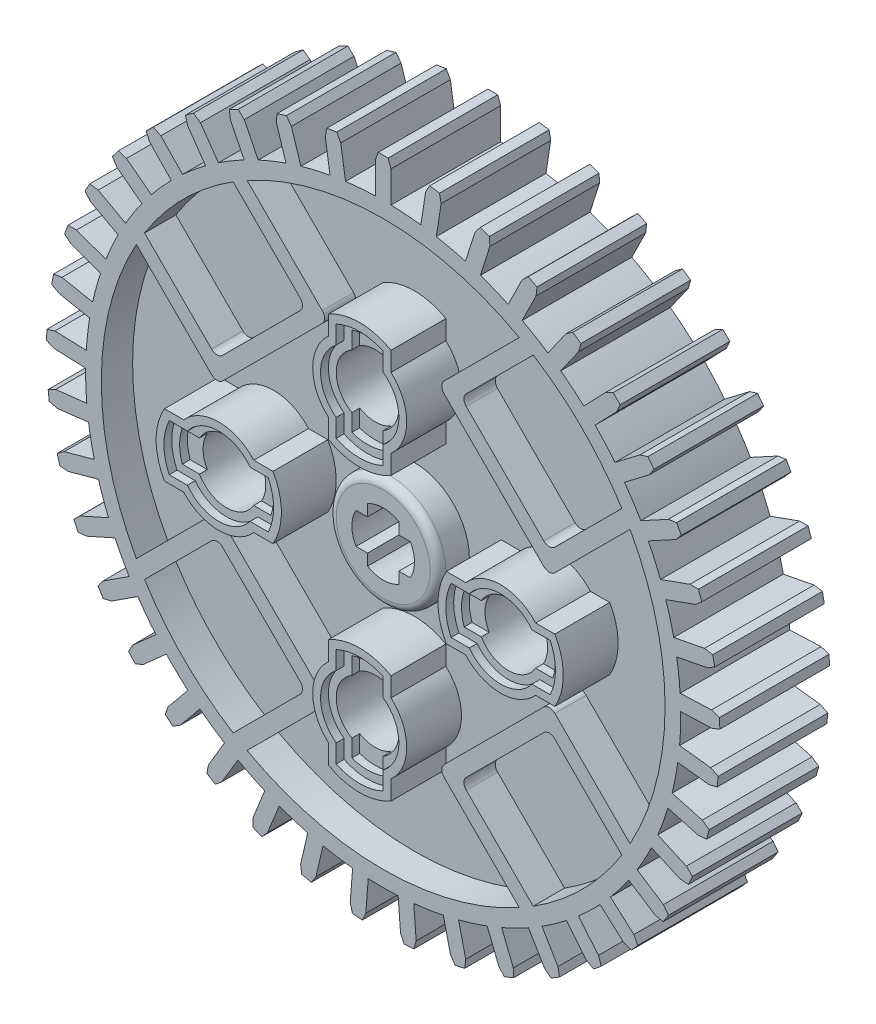
from build123d import *

# Parameters (mm, degrees)
SKETCH1_R                = 19
SKETCH1_R_2              = 2
BOSS_EXTRUDE1_DEPTH      = 3.5
SKETCH3_R                = 18
SKETCH3_R_2              = 3.5
CUT_EXTRUDE1_DEPTH       = 2
BOSS_EXTRUDE2_START      = -5
BOSS_EXTRUDE2_DEPTH      = 7
FILLET2_R                = 0.5
CIRPATTERN5_COUNT        = 4
FILLET2_OF_CIRPATTERN5_R = 0.5
BOSS_EXTRUDE3_DEPTH      = 3
CUT_EXTRUDE3_DEPTH       = 0.5
SKETCH8_R                = 2
CUT_EXTRUDE4_DEPTH       = 28.897132469
BOSS_EXTRUDE5_START      = -3
BOSS_EXTRUDE5_DEPTH      = 3.5
CIRPATTERN2_COUNT        = 4
MIRROR6_COPY_1_DEPTH     = 3
MIRROR6_COPY_2_DEPTH     = 3
MIRROR6_COPY_3_DEPTH     = 3
MIRROR6_COPY_4_DEPTH     = 0.5
MIRROR6_COPY_5_DEPTH     = 0.5
MIRROR6_COPY_6_DEPTH     = 0.5
MIRROR6_COPY_7_SKETCH_R  = 2
MIRROR6_COPY_7_DEPTH     = 28.897132469
MIRROR6_COPY_8_SKETCH_R  = 2
MIRROR6_COPY_8_DEPTH     = 28.897132469
MIRROR6_COPY_9_SKETCH_R  = 2
MIRROR6_COPY_9_DEPTH     = 28.897132469
MIRROR6_START            = -3
MIRROR6_COPY_10_DEPTH    = 3.5
MIRROR6_COPY_11_DEPTH    = 3.5
MIRROR6_COPY_12_DEPTH    = 3.5
MIRROR6_COPY_13_SKETCH_R = 2
MIRROR6_COPY_13_DEPTH    = 28.897132469
BOSS_EXTRUDE6_START      = -3.5
BOSS_EXTRUDE6_DEPTH      = 7
CIRPATTERN7_COUNT        = 41
FILLET3_R                = 0.5


with BuildPart() as part:
    # Sketch1 → Boss-Extrude1 (new, symmetric)
    with BuildSketch(Plane.XY):
        Circle(SKETCH1_R)
        Circle(SKETCH1_R_2, mode=Mode.SUBTRACT)
        with BuildLine():
            Line((1, -1), (1, -1.732050808))
            ThreePointArc((1, -1.732050808), (1.414213562, -1.414213562), (1.732050808, -1))
            Line((1.732050808, -1), (1, -1))
        make_face()
        with BuildLine():
            ThreePointArc((-1.732050808, -1), (-1.414213562, -1.414213562), (-1, -1.732050808))
            Line((-1, -1.732050808), (-1, -1))
            Line((-1, -1), (-1.732050808, -1))
        make_face()
        with BuildLine():
            Line((-1.732050808, 1), (-1, 1))
            Line((-1, 1), (-1, 1.732050808))
            ThreePointArc((-1, 1.732050808), (-1.414213562, 1.414213562), (-1.732050808, 1))
        make_face()
        with BuildLine():
            Line((1, 1.732050808), (1, 1))
            Line((1, 1), (1.732050808, 1))
            ThreePointArc((1.732050808, 1), (1.414213562, 1.414213562), (1, 1.732050808))
        make_face()
    extrude(amount=BOSS_EXTRUDE1_DEPTH, both=True)

    # Sketch3 → Cut-Extrude1 (cut)
    with BuildSketch(Plane.XY.offset(3.5)):
        Circle(SKETCH3_R)
        Circle(SKETCH3_R_2, mode=Mode.SUBTRACT)
    cut_extrude1 = extrude(amount=-CUT_EXTRUDE1_DEPTH, mode=Mode.SUBTRACT)

    # Mirror2: Cut-Extrude1 across plane
    add(cut_extrude1.mirror(Plane.XY), mode=Mode.SUBTRACT)

    # Sketch4 → Boss-Extrude2 (add)
    with BuildSketch(Plane.XY.offset(1.5).offset(BOSS_EXTRUDE2_START)):
        with BuildLine():
            Line((9.581246521, 15.238100771), (4.949747468, 10.606601718))
            Line((4.949747468, 10.606601718), (10.606601718, 4.949747468))
            Line((10.606601718, 4.949747468), (15.238100771, 9.581246521))
            ThreePointArc((15.238100771, 9.581246521), (15.506709995, 9.140128289), (15.762553167, 8.691485355))
            Line((15.762553167, 8.691485355), (10.606601718, 3.535533906))
            Line((10.606601718, 3.535533906), (3.535533906, 10.606601718))
            Line((3.535533906, 10.606601718), (8.691485355, 15.762553167))
            ThreePointArc((8.691485355, 15.762553167), (9.140128289, 15.506709995), (9.581246521, 15.238100771))
        make_face()
    boss_extrude2 = extrude(amount=BOSS_EXTRUDE2_DEPTH)

    # Fillet2
    fillet2_edges = [part.edges().sort_by_distance(p)[0] for p in [
        (3.535533906, 10.606601718, 2.5),
        (10.606601718, 4.949747468, 2.5),
        (10.606601718, 3.535533906, 2.5),
        (4.949747468, 10.606601718, 2.5),
        (3.535533906, 10.606601718, -2.5),
        (10.606601718, 3.535533906, -2.5),
        (10.606601718, 4.949747468, -2.5),
        (4.949747468, 10.606601718, -2.5),
    ]]
    fillet(fillet2_edges, radius=FILLET2_R)

    # CirPattern5: Boss-Extrude2 ×4 about axis
    cirpattern5_axis = Axis((0, 0, 0), (0, 0, 1))
    for i in range(1, CIRPATTERN5_COUNT):
        add(boss_extrude2.rotate(cirpattern5_axis, i * 360 / CIRPATTERN5_COUNT))

    # Fillet2 of CirPattern5
    fillet2_of_cirpattern5_edges = [part.edges().sort_by_distance(p)[0] for p in [
        (-10.606601718, 3.535533906, 2.5),
        (-4.949747468, 10.606601718, 2.5),
        (-3.535533906, 10.606601718, 2.5),
        (-10.606601718, 4.949747468, 2.5),
        (-10.606601718, 3.535533906, -2.5),
        (-3.535533906, 10.606601718, -2.5),
        (-4.949747468, 10.606601718, -2.5),
        (-10.606601718, 4.949747468, -2.5),
        (-3.535533906, -10.606601718, 2.5),
        (-10.606601718, -4.949747468, 2.5),
        (-10.606601718, -3.535533906, 2.5),
        (-4.949747468, -10.606601718, 2.5),
        (-3.535533906, -10.606601718, -2.5),
        (-10.606601718, -3.535533906, -2.5),
        (-10.606601718, -4.949747468, -2.5),
        (-4.949747468, -10.606601718, -2.5),
        (10.606601718, -3.535533906, 2.5),
        (4.949747468, -10.606601718, 2.5),
        (3.535533906, -10.606601718, 2.5),
        (10.606601718, -4.949747468, 2.5),
        (10.606601718, -3.535533906, -2.5),
        (3.535533906, -10.606601718, -2.5),
        (4.949747468, -10.606601718, -2.5),
        (10.606601718, -4.949747468, -2.5),
    ]]
    fillet(fillet2_of_cirpattern5_edges, radius=FILLET2_OF_CIRPATTERN5_R)

    # Sketch5 → Boss-Extrude3 (add)
    with BuildSketch(Plane.XY.offset(1.5)):
        with BuildLine():
            ThreePointArc((-1.5, 11), (-2.5, 9), (-1.5, 7))
            Line((-1.5, 7), (-1.5, 11))
        make_face()
        with BuildLine():
            Line((1.5, 11), (1.5, 7))
            ThreePointArc((1.5, 7), (2.236067977, 7.881966011), (2.5, 9))
            ThreePointArc((2.5, 9), (2.236067977, 10.118033989), (1.5, 11))
        make_face()
        with BuildLine():
            Line((-1.5, 7), (-1.5, 5.83772234))
            Line((-1.5, 5.83772234), (1.5, 5.83772234))
            Line((1.5, 5.83772234), (1.5, 7))
            ThreePointArc((1.5, 7), (0, 6.5), (-1.5, 7))
        make_face()
        with BuildLine():
            Line((1.5, 5.83772234), (-1.5, 5.83772234))
            ThreePointArc((-1.5, 5.83772234), (0, 5.5), (1.5, 5.83772234))
        make_face()
        with BuildLine():
            Line((1.5, 12.16227766), (-1.5, 12.16227766))
            Line((-1.5, 12.16227766), (-1.5, 11))
            ThreePointArc((-1.5, 11), (0, 11.5), (1.5, 11))
            Line((1.5, 11), (1.5, 12.16227766))
        make_face()
        with BuildLine():
            ThreePointArc((1.5, 12.16227766), (0, 12.5), (-1.5, 12.16227766))
            Line((-1.5, 12.16227766), (1.5, 12.16227766))
        make_face()
        with BuildLine():
            Line((-1.5, 11), (-1.5, 7))
            ThreePointArc((-1.5, 7), (0, 6.5), (1.5, 7))
            Line((1.5, 7), (1.5, 11))
            ThreePointArc((1.5, 11), (0, 11.5), (-1.5, 11))
        make_face()
    boss_extrude3 = extrude(amount=BOSS_EXTRUDE3_DEPTH)

    # Sketch7 → Cut-Extrude3 (cut)
    with BuildSketch(Plane.XY.offset(4.5)):
        with BuildLine():
            Line((-1, 7.267949192), (-1, 6.171572875))
            ThreePointArc((-1, 6.171572875), (0, 6), (1, 6.171572875))
            Line((1, 6.171572875), (1, 7.267949192))
            ThreePointArc((1, 7.267949192), (2, 9), (1, 10.732050808))
            Line((1, 10.732050808), (1, 11.828427125))
            ThreePointArc((1, 11.828427125), (0, 12), (-1, 11.828427125))
            Line((-1, 11.828427125), (-1, 10.732050808))
            ThreePointArc((-1, 10.732050808), (-2, 9), (-1, 7.267949192))
        make_face()
    cut_extrude3 = extrude(amount=-CUT_EXTRUDE3_DEPTH, mode=Mode.SUBTRACT)

    # Sketch8 → Cut-Extrude4 (cut, symmetric)
    with BuildSketch(Plane.XY.offset(4)):
        with Locations(Location((0, 9, 0), (0, 0, 300))):
            Circle(SKETCH8_R)
    cut_extrude4 = extrude(amount=CUT_EXTRUDE4_DEPTH, both=True, mode=Mode.SUBTRACT)

    # Sketch9 → Boss-Extrude5 (add)
    with BuildSketch(Plane.XY.offset(4.5).offset(BOSS_EXTRUDE5_START)):
        with BuildLine():
            Line((-2, 6.763932023), (-2, 5.535898385))
            ThreePointArc((-2, 5.535898385), (0, 5), (2, 5.535898385))
            Line((2, 5.535898385), (2, 6.763932023))
            ThreePointArc((2, 6.763932023), (3, 9), (2, 11.236067977))
            Line((2, 11.236067977), (2, 12.464101615))
            ThreePointArc((2, 12.464101615), (0, 13), (-2, 12.464101615))
            Line((-2, 12.464101615), (-2, 11.236067977))
            ThreePointArc((-2, 11.236067977), (-3, 9), (-2, 6.763932023))
        make_face()
        with BuildLine():
            Line((-1.5, 7), (-1.5, 5.83772234))
            ThreePointArc((-1.5, 5.83772234), (0, 5.5), (1.5, 5.83772234))
            Line((1.5, 5.83772234), (1.5, 7))
            ThreePointArc((1.5, 7), (2.5, 9), (1.5, 11))
            Line((1.5, 11), (1.5, 12.16227766))
            ThreePointArc((1.5, 12.16227766), (0, 12.5), (-1.5, 12.16227766))
            Line((-1.5, 12.16227766), (-1.5, 11))
            ThreePointArc((-1.5, 11), (-2.5, 9), (-1.5, 7))
        make_face(mode=Mode.SUBTRACT)
    boss_extrude5 = extrude(amount=BOSS_EXTRUDE5_DEPTH)

    # CirPattern2: Boss-Extrude3, Cut-Extrude3, Cut-Extrude4, Boss-Extrude5 ×4 about axis
    cirpattern2_axis = Axis((0, 0, 0), (0, 0, 1))
    add([boss_extrude3.rotate(cirpattern2_axis, i * 360 / CIRPATTERN2_COUNT) for i in range(1, CIRPATTERN2_COUNT)])
    add([cut_extrude3.rotate(cirpattern2_axis, i * 360 / CIRPATTERN2_COUNT) for i in range(1, CIRPATTERN2_COUNT)], mode=Mode.SUBTRACT)
    add([cut_extrude4.rotate(cirpattern2_axis, i * 360 / CIRPATTERN2_COUNT) for i in range(1, CIRPATTERN2_COUNT)], mode=Mode.SUBTRACT)
    add([boss_extrude5.rotate(cirpattern2_axis, i * 360 / CIRPATTERN2_COUNT) for i in range(1, CIRPATTERN2_COUNT)])

    # Mirror6: Boss-Extrude3, Cut-Extrude3, Boss-Extrude5 across plane
    add(boss_extrude3.mirror(Plane.XY))
    add(cut_extrude3.mirror(Plane.XY), mode=Mode.SUBTRACT)
    add(boss_extrude5.mirror(Plane.XY))

    # Mirror6 copy 1 sketch → Mirror6 copy 1 (add)
    with BuildSketch(Plane.YX.offset(1.5)):
        with BuildLine():
            ThreePointArc((-1.5, -11), (-2.5, -9), (-1.5, -7))
            Line((-1.5, -7), (-1.5, -11))
        make_face()
        with BuildLine():
            Line((1.5, -11), (1.5, -7))
            ThreePointArc((1.5, -7), (2.236067977, -7.881966011), (2.5, -9))
            ThreePointArc((2.5, -9), (2.236067977, -10.118033989), (1.5, -11))
        make_face()
        with BuildLine():
            Line((-1.5, -7), (-1.5, -5.83772234))
            Line((-1.5, -5.83772234), (1.5, -5.83772234))
            Line((1.5, -5.83772234), (1.5, -7))
            ThreePointArc((1.5, -7), (0, -6.5), (-1.5, -7))
        make_face()
        with BuildLine():
            Line((1.5, -5.83772234), (-1.5, -5.83772234))
            ThreePointArc((-1.5, -5.83772234), (0, -5.5), (1.5, -5.83772234))
        make_face()
        with BuildLine():
            Line((1.5, -12.16227766), (-1.5, -12.16227766))
            Line((-1.5, -12.16227766), (-1.5, -11))
            ThreePointArc((-1.5, -11), (0, -11.5), (1.5, -11))
            Line((1.5, -11), (1.5, -12.16227766))
        make_face()
        with BuildLine():
            ThreePointArc((1.5, -12.16227766), (0, -12.5), (-1.5, -12.16227766))
            Line((-1.5, -12.16227766), (1.5, -12.16227766))
        make_face()
        with BuildLine():
            Line((-1.5, -11), (-1.5, -7))
            ThreePointArc((-1.5, -7), (0, -6.5), (1.5, -7))
            Line((1.5, -7), (1.5, -11))
            ThreePointArc((1.5, -11), (0, -11.5), (-1.5, -11))
        make_face()
    extrude(amount=MIRROR6_COPY_1_DEPTH)

    # Mirror6 copy 2 sketch → Mirror6 copy 2 (add)
    with BuildSketch(Plane(origin=(0, 0, -1.5), x_dir=(-1, 0, 0), z_dir=(0, 0, -1))):
        with BuildLine():
            ThreePointArc((-1.5, -11), (-2.5, -9), (-1.5, -7))
            Line((-1.5, -7), (-1.5, -11))
        make_face()
        with BuildLine():
            Line((1.5, -11), (1.5, -7))
            ThreePointArc((1.5, -7), (2.236067977, -7.881966011), (2.5, -9))
            ThreePointArc((2.5, -9), (2.236067977, -10.118033989), (1.5, -11))
        make_face()
        with BuildLine():
            Line((-1.5, -7), (-1.5, -5.83772234))
            Line((-1.5, -5.83772234), (1.5, -5.83772234))
            Line((1.5, -5.83772234), (1.5, -7))
            ThreePointArc((1.5, -7), (0, -6.5), (-1.5, -7))
        make_face()
        with BuildLine():
            Line((1.5, -5.83772234), (-1.5, -5.83772234))
            ThreePointArc((-1.5, -5.83772234), (0, -5.5), (1.5, -5.83772234))
        make_face()
        with BuildLine():
            Line((1.5, -12.16227766), (-1.5, -12.16227766))
            Line((-1.5, -12.16227766), (-1.5, -11))
            ThreePointArc((-1.5, -11), (0, -11.5), (1.5, -11))
            Line((1.5, -11), (1.5, -12.16227766))
        make_face()
        with BuildLine():
            ThreePointArc((1.5, -12.16227766), (0, -12.5), (-1.5, -12.16227766))
            Line((-1.5, -12.16227766), (1.5, -12.16227766))
        make_face()
        with BuildLine():
            Line((-1.5, -11), (-1.5, -7))
            ThreePointArc((-1.5, -7), (0, -6.5), (1.5, -7))
            Line((1.5, -7), (1.5, -11))
            ThreePointArc((1.5, -11), (0, -11.5), (-1.5, -11))
        make_face()
    extrude(amount=MIRROR6_COPY_2_DEPTH)

    # Mirror6 copy 3 sketch → Mirror6 copy 3 (add)
    with BuildSketch(Plane(origin=(0, 0, -1.5), x_dir=(0, -1, 0), z_dir=(0, 0, -1))):
        with BuildLine():
            ThreePointArc((-1.5, -11), (-2.5, -9), (-1.5, -7))
            Line((-1.5, -7), (-1.5, -11))
        make_face()
        with BuildLine():
            Line((1.5, -11), (1.5, -7))
            ThreePointArc((1.5, -7), (2.236067977, -7.881966011), (2.5, -9))
            ThreePointArc((2.5, -9), (2.236067977, -10.118033989), (1.5, -11))
        make_face()
        with BuildLine():
            Line((-1.5, -7), (-1.5, -5.83772234))
            Line((-1.5, -5.83772234), (1.5, -5.83772234))
            Line((1.5, -5.83772234), (1.5, -7))
            ThreePointArc((1.5, -7), (0, -6.5), (-1.5, -7))
        make_face()
        with BuildLine():
            Line((1.5, -5.83772234), (-1.5, -5.83772234))
            ThreePointArc((-1.5, -5.83772234), (0, -5.5), (1.5, -5.83772234))
        make_face()
        with BuildLine():
            Line((1.5, -12.16227766), (-1.5, -12.16227766))
            Line((-1.5, -12.16227766), (-1.5, -11))
            ThreePointArc((-1.5, -11), (0, -11.5), (1.5, -11))
            Line((1.5, -11), (1.5, -12.16227766))
        make_face()
        with BuildLine():
            ThreePointArc((1.5, -12.16227766), (0, -12.5), (-1.5, -12.16227766))
            Line((-1.5, -12.16227766), (1.5, -12.16227766))
        make_face()
        with BuildLine():
            Line((-1.5, -11), (-1.5, -7))
            ThreePointArc((-1.5, -7), (0, -6.5), (1.5, -7))
            Line((1.5, -7), (1.5, -11))
            ThreePointArc((1.5, -11), (0, -11.5), (-1.5, -11))
        make_face()
    extrude(amount=MIRROR6_COPY_3_DEPTH)

    # Mirror6 copy 4 sketch → Mirror6 copy 4 (cut)
    with BuildSketch(Plane.YX.offset(4.5)):
        with BuildLine():
            Line((-1, -7.267949192), (-1, -6.171572875))
            ThreePointArc((-1, -6.171572875), (0, -6), (1, -6.171572875))
            Line((1, -6.171572875), (1, -7.267949192))
            ThreePointArc((1, -7.267949192), (2, -9), (1, -10.732050808))
            Line((1, -10.732050808), (1, -11.828427125))
            ThreePointArc((1, -11.828427125), (0, -12), (-1, -11.828427125))
            Line((-1, -11.828427125), (-1, -10.732050808))
            ThreePointArc((-1, -10.732050808), (-2, -9), (-1, -7.267949192))
        make_face()
    extrude(amount=-MIRROR6_COPY_4_DEPTH, mode=Mode.SUBTRACT)

    # Mirror6 copy 5 sketch → Mirror6 copy 5 (cut)
    with BuildSketch(Plane(origin=(0, 0, -4.5), x_dir=(-1, 0, 0), z_dir=(0, 0, -1))):
        with BuildLine():
            Line((-1, -7.267949192), (-1, -6.171572875))
            ThreePointArc((-1, -6.171572875), (0, -6), (1, -6.171572875))
            Line((1, -6.171572875), (1, -7.267949192))
            ThreePointArc((1, -7.267949192), (2, -9), (1, -10.732050808))
            Line((1, -10.732050808), (1, -11.828427125))
            ThreePointArc((1, -11.828427125), (0, -12), (-1, -11.828427125))
            Line((-1, -11.828427125), (-1, -10.732050808))
            ThreePointArc((-1, -10.732050808), (-2, -9), (-1, -7.267949192))
        make_face()
    extrude(amount=-MIRROR6_COPY_5_DEPTH, mode=Mode.SUBTRACT)

    # Mirror6 copy 6 sketch → Mirror6 copy 6 (cut)
    with BuildSketch(Plane(origin=(0, 0, -4.5), x_dir=(0, -1, 0), z_dir=(0, 0, -1))):
        with BuildLine():
            Line((-1, -7.267949192), (-1, -6.171572875))
            ThreePointArc((-1, -6.171572875), (0, -6), (1, -6.171572875))
            Line((1, -6.171572875), (1, -7.267949192))
            ThreePointArc((1, -7.267949192), (2, -9), (1, -10.732050808))
            Line((1, -10.732050808), (1, -11.828427125))
            ThreePointArc((1, -11.828427125), (0, -12), (-1, -11.828427125))
            Line((-1, -11.828427125), (-1, -10.732050808))
            ThreePointArc((-1, -10.732050808), (-2, -9), (-1, -7.267949192))
        make_face()
    extrude(amount=-MIRROR6_COPY_6_DEPTH, mode=Mode.SUBTRACT)

    # Mirror6 copy 7 sketch → Mirror6 copy 7 (cut, symmetric)
    with BuildSketch(Plane.YX.offset(4)):
        with Locations((0, -9)):
            Circle(MIRROR6_COPY_7_SKETCH_R)
    extrude(amount=MIRROR6_COPY_7_DEPTH, both=True, mode=Mode.SUBTRACT)

    # Mirror6 copy 8 sketch → Mirror6 copy 8 (cut, symmetric)
    with BuildSketch(Plane(origin=(0, 0, -4), x_dir=(-1, 0, 0), z_dir=(0, 0, -1))):
        with Locations((0, -9)):
            Circle(MIRROR6_COPY_8_SKETCH_R)
    extrude(amount=MIRROR6_COPY_8_DEPTH, both=True, mode=Mode.SUBTRACT)

    # Mirror6 copy 9 sketch → Mirror6 copy 9 (cut, symmetric)
    with BuildSketch(Plane(origin=(0, 0, -4), x_dir=(0, -1, 0), z_dir=(0, 0, -1))):
        with Locations((0, -9)):
            Circle(MIRROR6_COPY_9_SKETCH_R)
    extrude(amount=MIRROR6_COPY_9_DEPTH, both=True, mode=Mode.SUBTRACT)

    # Mirror6 copy 10 sketch → Mirror6 copy 10 (add)
    with BuildSketch(Plane.YX.offset(4.5).offset(MIRROR6_START)):
        with BuildLine():
            Line((-2, -6.763932023), (-2, -5.535898385))
            ThreePointArc((-2, -5.535898385), (0, -5), (2, -5.535898385))
            Line((2, -5.535898385), (2, -6.763932023))
            ThreePointArc((2, -6.763932023), (3, -9), (2, -11.236067977))
            Line((2, -11.236067977), (2, -12.464101615))
            ThreePointArc((2, -12.464101615), (0, -13), (-2, -12.464101615))
            Line((-2, -12.464101615), (-2, -11.236067977))
            ThreePointArc((-2, -11.236067977), (-3, -9), (-2, -6.763932023))
        make_face()
        with BuildLine():
            Line((-1.5, -7), (-1.5, -5.83772234))
            ThreePointArc((-1.5, -5.83772234), (0, -5.5), (1.5, -5.83772234))
            Line((1.5, -5.83772234), (1.5, -7))
            ThreePointArc((1.5, -7), (2.5, -9), (1.5, -11))
            Line((1.5, -11), (1.5, -12.16227766))
            ThreePointArc((1.5, -12.16227766), (0, -12.5), (-1.5, -12.16227766))
            Line((-1.5, -12.16227766), (-1.5, -11))
            ThreePointArc((-1.5, -11), (-2.5, -9), (-1.5, -7))
        make_face(mode=Mode.SUBTRACT)
    extrude(amount=MIRROR6_COPY_10_DEPTH)

    # Mirror6 copy 11 sketch → Mirror6 copy 11 (add)
    with BuildSketch(Plane(origin=(0, 0, -4.5), x_dir=(-1, 0, 0), z_dir=(0, 0, -1)).offset(MIRROR6_START)):
        with BuildLine():
            Line((-2, -6.763932023), (-2, -5.535898385))
            ThreePointArc((-2, -5.535898385), (0, -5), (2, -5.535898385))
            Line((2, -5.535898385), (2, -6.763932023))
            ThreePointArc((2, -6.763932023), (3, -9), (2, -11.236067977))
            Line((2, -11.236067977), (2, -12.464101615))
            ThreePointArc((2, -12.464101615), (0, -13), (-2, -12.464101615))
            Line((-2, -12.464101615), (-2, -11.236067977))
            ThreePointArc((-2, -11.236067977), (-3, -9), (-2, -6.763932023))
        make_face()
        with BuildLine():
            Line((-1.5, -7), (-1.5, -5.83772234))
            ThreePointArc((-1.5, -5.83772234), (0, -5.5), (1.5, -5.83772234))
            Line((1.5, -5.83772234), (1.5, -7))
            ThreePointArc((1.5, -7), (2.5, -9), (1.5, -11))
            Line((1.5, -11), (1.5, -12.16227766))
            ThreePointArc((1.5, -12.16227766), (0, -12.5), (-1.5, -12.16227766))
            Line((-1.5, -12.16227766), (-1.5, -11))
            ThreePointArc((-1.5, -11), (-2.5, -9), (-1.5, -7))
        make_face(mode=Mode.SUBTRACT)
    extrude(amount=MIRROR6_COPY_11_DEPTH)

    # Mirror6 copy 12 sketch → Mirror6 copy 12 (add)
    with BuildSketch(Plane(origin=(0, 0, -4.5), x_dir=(0, -1, 0), z_dir=(0, 0, -1)).offset(MIRROR6_START)):
        with BuildLine():
            Line((-2, -6.763932023), (-2, -5.535898385))
            ThreePointArc((-2, -5.535898385), (0, -5), (2, -5.535898385))
            Line((2, -5.535898385), (2, -6.763932023))
            ThreePointArc((2, -6.763932023), (3, -9), (2, -11.236067977))
            Line((2, -11.236067977), (2, -12.464101615))
            ThreePointArc((2, -12.464101615), (0, -13), (-2, -12.464101615))
            Line((-2, -12.464101615), (-2, -11.236067977))
            ThreePointArc((-2, -11.236067977), (-3, -9), (-2, -6.763932023))
        make_face()
        with BuildLine():
            Line((-1.5, -7), (-1.5, -5.83772234))
            ThreePointArc((-1.5, -5.83772234), (0, -5.5), (1.5, -5.83772234))
            Line((1.5, -5.83772234), (1.5, -7))
            ThreePointArc((1.5, -7), (2.5, -9), (1.5, -11))
            Line((1.5, -11), (1.5, -12.16227766))
            ThreePointArc((1.5, -12.16227766), (0, -12.5), (-1.5, -12.16227766))
            Line((-1.5, -12.16227766), (-1.5, -11))
            ThreePointArc((-1.5, -11), (-2.5, -9), (-1.5, -7))
        make_face(mode=Mode.SUBTRACT)
    extrude(amount=MIRROR6_COPY_12_DEPTH)

    # Mirror6 copy 13 sketch → Mirror6 copy 13 (cut, symmetric)
    with BuildSketch(Plane(origin=(0, 0, -4), x_dir=(1, 0, 0), z_dir=(0, 0, -1))):
        with Locations((0, -9)):
            Circle(MIRROR6_COPY_13_SKETCH_R)
    extrude(amount=MIRROR6_COPY_13_DEPTH, both=True, mode=Mode.SUBTRACT)

    # Sketch10 → Boss-Extrude6 (add)
    with BuildSketch(Plane.XY.offset(BOSS_EXTRUDE6_START)):
        with BuildLine():
            Line((-0.5, 18.993419913), (-0.5, 20.993419913))
            Line((-0.5, 20.993419913), (-0.315619927, 21.5))
            Line((-0.315619927, 21.5), (0.315619927, 21.5))
            Line((0.315619927, 21.5), (0.5, 20.993419913))
            Line((0.5, 20.993419913), (0.5, 18.993419913))
            ThreePointArc((0.5, 18.993419913), (0, 19), (-0.5, 18.993419913))
        make_face()
    boss_extrude6 = extrude(amount=BOSS_EXTRUDE6_DEPTH)

    # CirPattern7: Boss-Extrude6 ×41 about axis
    cirpattern7_axis = Axis((0, 0, 0), (0, 0, 1))
    for i in range(1, CIRPATTERN7_COUNT):
        add(boss_extrude6.rotate(cirpattern7_axis, i * 360 / CIRPATTERN7_COUNT))

    # Fillet3
    fillet3_edges = [part.edges().sort_by_distance(p)[0] for p in [
        (-3.5, 0, 3.5),
        (-3.5, 0, -3.5),
    ]]
    fillet(fillet3_edges, radius=FILLET3_R)


solid = part.part
